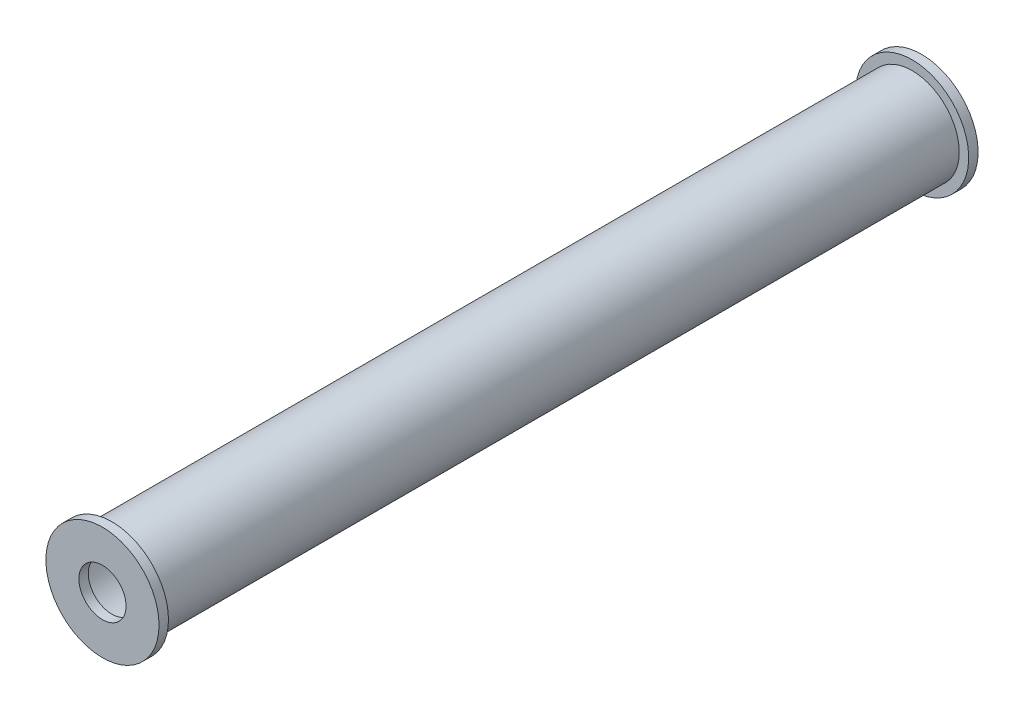
from build123d import *

# Parameters (mm, degrees)
SKETCH1_R           = 5
SKETCH1_R_2         = 4.5
BOSS_EXTRUDE1_DEPTH = 84.88
SKETCH2_R           = 6
SKETCH2_R_2         = 2.5
BOSS_EXTRUDE2_DEPTH = 1
SKETCH3_R           = 6
SKETCH3_R_2         = 2.5
BOSS_EXTRUDE3_DEPTH = 1


with BuildPart() as part:
    # Sketch1 → Boss-Extrude1 (new body)
    with BuildSketch(Plane.XY):
        Circle(SKETCH1_R)
        Circle(SKETCH1_R_2, mode=Mode.SUBTRACT)
    extrude(amount=BOSS_EXTRUDE1_DEPTH)

    # Sketch2 → Boss-Extrude2 (add)
    with BuildSketch(Plane(origin=(0, 0, 0), x_dir=(-1, 0, 0), z_dir=(0, 0, -1))):
        Circle(SKETCH2_R)
        Circle(SKETCH2_R_2, mode=Mode.SUBTRACT)
    extrude(amount=BOSS_EXTRUDE2_DEPTH)

    # Sketch3 → Boss-Extrude3 (add)
    with BuildSketch(Plane.XY.offset(84.88)):
        Circle(SKETCH3_R)
        Circle(SKETCH3_R_2, mode=Mode.SUBTRACT)
    extrude(amount=BOSS_EXTRUDE3_DEPTH)


solid = part.part
